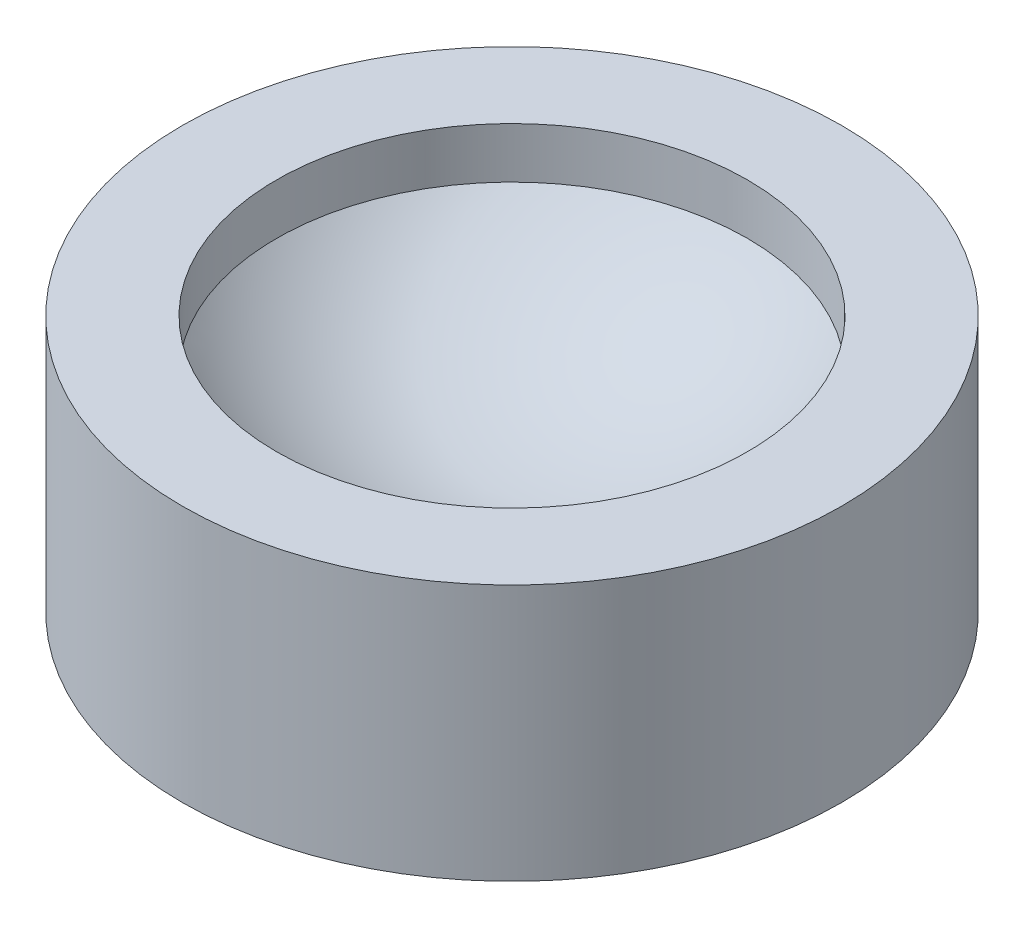
from build123d import *

# Parameters (mm, degrees)
SKETCH1_R           = 10.5
BOSS_EXTRUDE1_DEPTH = 8.17408016


with BuildPart() as part:
    # Sketch1 → Boss-Extrude1 (new body)
    with BuildSketch(Plane(origin=(0, 0, 0), x_dir=(1, 0, 0), z_dir=(0, 1, 0))):
        Circle(SKETCH1_R)
    extrude(amount=BOSS_EXTRUDE1_DEPTH)

    # Sketch2 → Cut-Revolve2 (revolve, cut)
    with BuildSketch(Plane(origin=(0, 0, 0), x_dir=(0, 0, -1), z_dir=(1, 0, 0))):
        with BuildLine():
            Line((0, 8.17408016), (7.5, 8.17408016))
            Line((7.5, 8.17408016), (7.5, 6.559701883))
            ThreePointArc((7.5, 6.559701883), (4.114378278, 4.059701883), (0, 3.17408016))
            Line((0, 3.17408016), (0, 8.17408016))
        make_face()
    revolve(axis=Axis((0, 0.049098768, 0), (0, 1, 0)), mode=Mode.SUBTRACT)


solid = part.part
